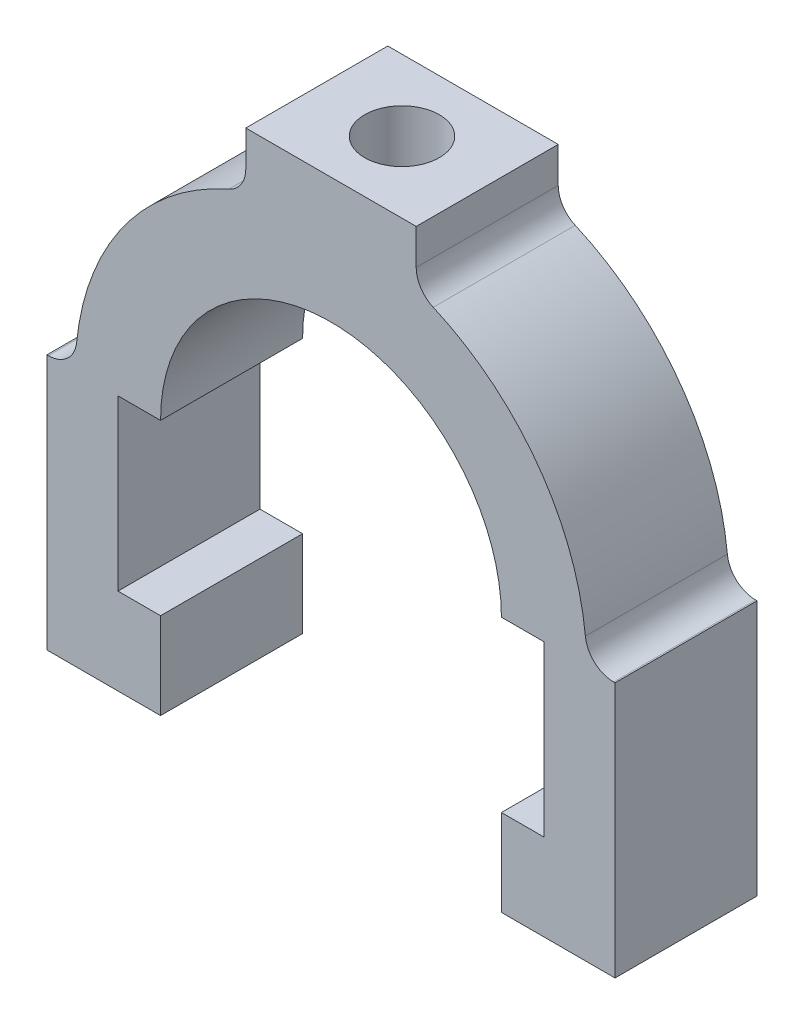
from build123d import *

# Parameters (mm, degrees)
Y_KSEKLIK_EKSTR_ZYON1_DEPTH = 20
IZIM2_R                     = 5.251294355
KES_EKSTR_ZYON1_DEPTH       = 35


with BuildPart() as part:
    # Çizim1 → Yükseklik-Ekstrüzyon1 (new body)
    with BuildSketch(Plane.XY):
        with BuildLine():
            Line((39.799497484, 0), (40, 0))
            Line((40, 0), (40, -36))
            Line((40, -36), (24, -36))
            Line((24, -36), (24, -23.81673939))
            Line((24, -23.81673939), (30, -23.81673939))
            Line((30, -23.81673939), (30, 0))
            Line((30, 0), (24, 0))
            ThreePointArc((24, 0), (0, 24), (-24, 0))
            Line((-24, 0), (-30, 0))
            Line((-30, 0), (-30, -23.81673939))
            Line((-30, -23.81673939), (-24, -23.81673939))
            Line((-24, -23.81673939), (-24, -36))
            Line((-24, -36), (-40, -36))
            Line((-40, -36), (-40, 0))
            Line((-40, 0), (-39.799497484, 0))
            ThreePointArc((-39.799497484, 0), (-37.116215911, 1.033520605), (-35.819547736, 3.6))
            ThreePointArc((-35.819547736, 3.6), (-29.094854574, 21.201165942), (-14.4, 32.994545004))
            ThreePointArc((-14.4, 32.994545004), (-12.653359894, 34.46971533), (-12, 36.66060556))
            Line((-12, 36.66060556), (-12, 41.66060556))
            Line((-12, 41.66060556), (12, 41.66060556))
            Line((12, 41.66060556), (12, 36.66060556))
            ThreePointArc((12, 36.66060556), (12.653359894, 34.46971533), (14.4, 32.994545004))
            ThreePointArc((14.4, 32.994545004), (29.094854574, 21.201165942), (35.819547736, 3.6))
            ThreePointArc((35.819547736, 3.6), (37.116215911, 1.033520605), (39.799497484, 0))
        make_face()
    extrude(amount=Y_KSEKLIK_EKSTR_ZYON1_DEPTH)

    # Çizim2 → Kes-Ekstrüzyon1 (cut)
    with BuildSketch(Plane(origin=(0, 41.66060556, 0), x_dir=(1, 0, 0), z_dir=(0, 1, 0))):
        with Locations((0, -10)):
            Circle(IZIM2_R)
    extrude(amount=-KES_EKSTR_ZYON1_DEPTH, mode=Mode.SUBTRACT)


solid = part.part
